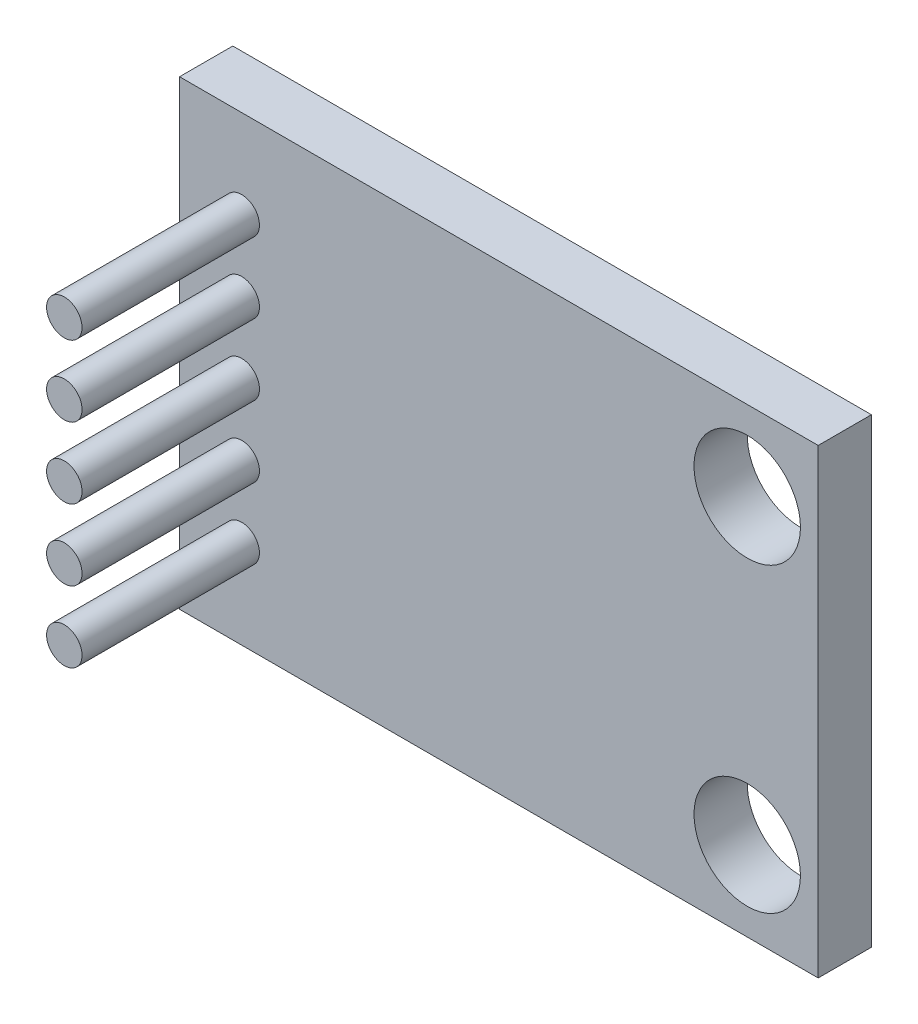
from build123d import *

# Parameters (mm, degrees)
SKETCH1_W           = 18
SKETCH1_H           = 13
BOSS_EXTRUDE1_DEPTH = 1.5
SKETCH2_R           = 0.5
BOSS_EXTRUDE2_DEPTH = 5
CUT_EXTRUDE1_REACH  = 3.5
SKETCH3_R           = 1.5


with BuildPart() as part:
    # Sketch1 → Boss-Extrude1 (new body)
    with BuildSketch(Plane.XY):
        with Locations((165.583059714, 53.307197022)):
            Rectangle(SKETCH1_W, SKETCH1_H)
    extrude(amount=BOSS_EXTRUDE1_DEPTH)

    # Sketch2 → Boss-Extrude2 (add)
    with BuildSketch(Plane.XY.offset(1.5)):
        with Locations((158.334176002, 53.307197022)):
            Circle(SKETCH2_R)
        with Locations((158.334176002, 55.307197022)):
            Circle(SKETCH2_R)
        with Locations((158.334176002, 57.307197022)):
            Circle(SKETCH2_R)
        with Locations((158.334176002, 51.307197022)):
            Circle(SKETCH2_R)
        with Locations((158.334176002, 49.307197022)):
            Circle(SKETCH2_R)
    extrude(amount=BOSS_EXTRUDE2_DEPTH)

    # Sketch3 → Cut-Extrude1 (cut, up to next)
    with BuildSketch(Plane.XY.offset(1.5), mode=Mode.PRIVATE) as cut_extrude1_sk1:
        with Locations((172.583059714, 57.557197022)):
            Circle(SKETCH3_R)
    cut_extrude1_tool1 = extrude(cut_extrude1_sk1.sketch, amount=-CUT_EXTRUDE1_REACH, mode=Mode.PRIVATE) & part.part
    add(cut_extrude1_tool1.solids().sort_by_distance((172.58306, 57.557197, 1.5))[0], mode=Mode.SUBTRACT)
    # Sketch3 → Cut-Extrude1 (cut, up to next)
    with BuildSketch(Plane.XY.offset(1.5), mode=Mode.PRIVATE) as cut_extrude1_sk2:
        with Locations((172.583059714, 49.057197022)):
            Circle(SKETCH3_R)
    cut_extrude1_tool2 = extrude(cut_extrude1_sk2.sketch, amount=-CUT_EXTRUDE1_REACH, mode=Mode.PRIVATE) & part.part
    add(cut_extrude1_tool2.solids().sort_by_distance((172.58306, 49.057197, 1.5))[0], mode=Mode.SUBTRACT)


solid = part.part
